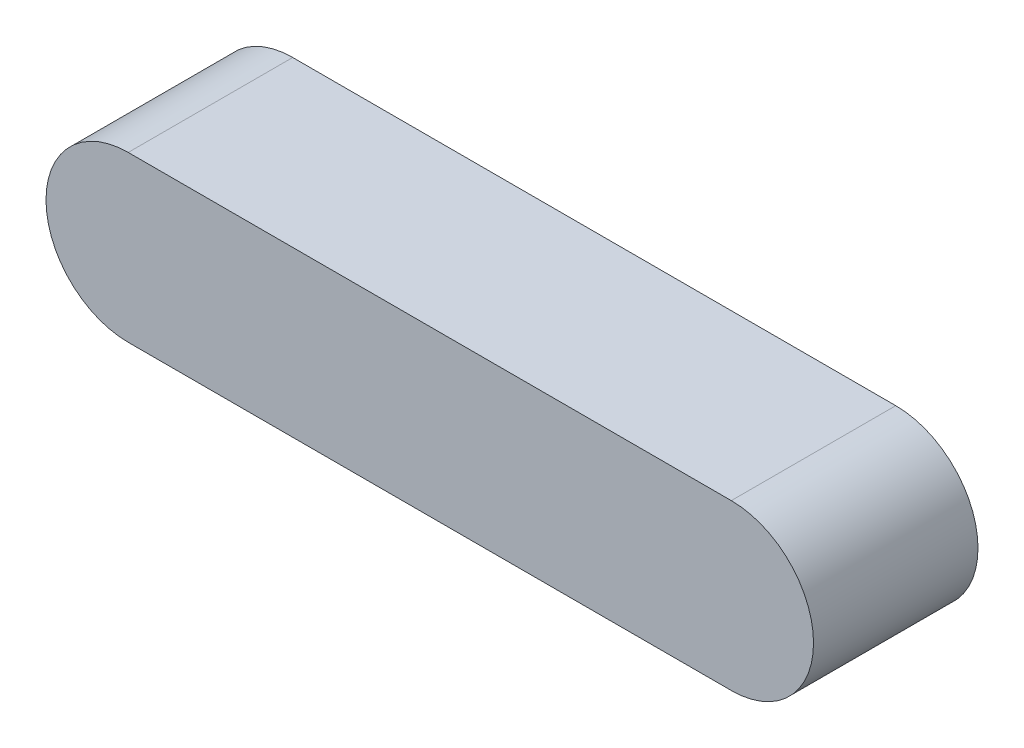
from build123d import *

# Parameters (mm, degrees)
BOSS_EXTRUDE1_DEPTH = 3


with BuildPart() as part:
    # Sketch1 → Boss-Extrude1 (new body)
    with BuildSketch(Plane.XY):
        with BuildLine():
            Line((-5.5, 1.5), (5.5, 1.5))
            ThreePointArc((5.5, 1.5), (7, 0), (5.5, -1.5))
            Line((5.5, -1.5), (-5.5, -1.5))
            ThreePointArc((-5.5, -1.5), (-7, 0), (-5.5, 1.5))
        make_face()
    extrude(amount=BOSS_EXTRUDE1_DEPTH)


solid = part.part
